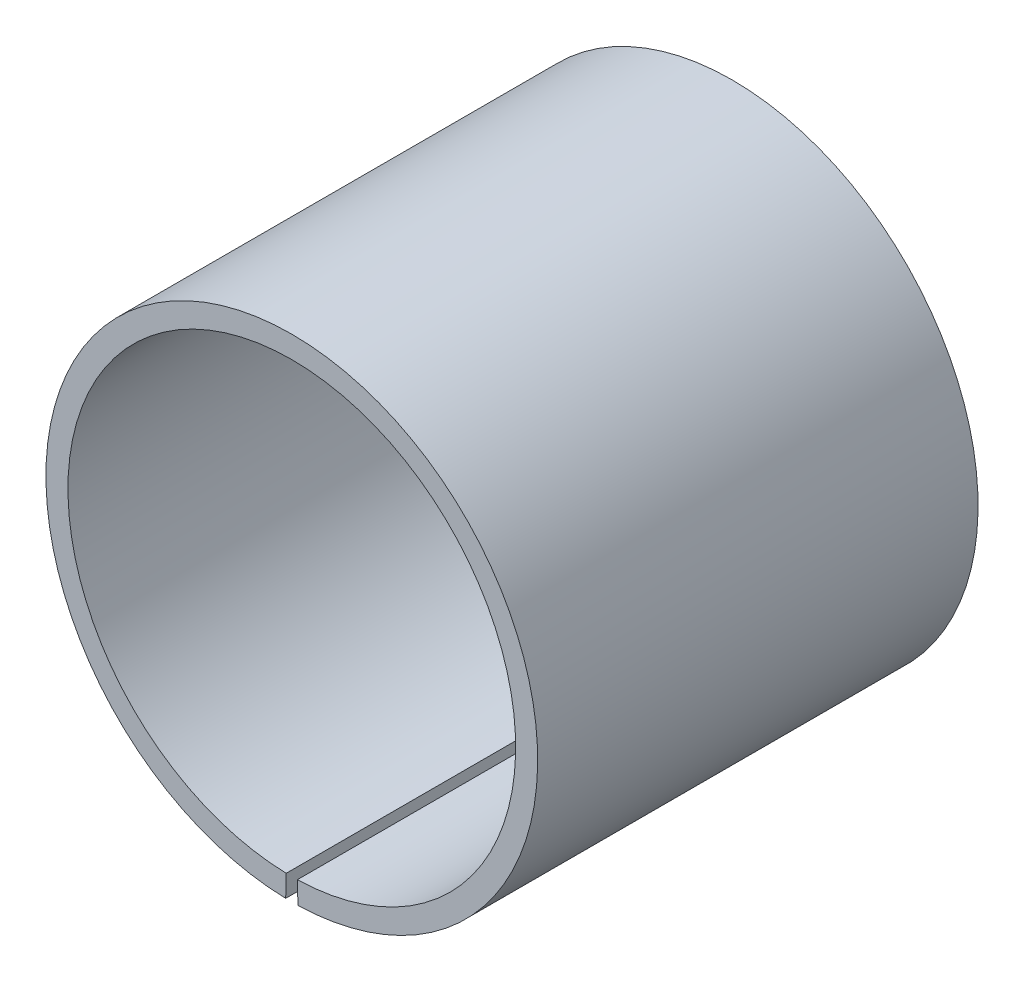
from build123d import *

# Parameters (mm, degrees)
BOSS_EXTRUDE1_DEPTH = 15


with BuildPart() as part:
    # Sketch1 → Boss-Extrude1 (new body, symmetric)
    with BuildSketch(Plane.XY):
        with BuildLine():
            Line((-0.379746263, -15.245271161), (-0.417098355, -16.744806029))
            ThreePointArc((-0.417098355, -16.744806029), (0, 16.75), (0.417098355, -16.744806029))
            Line((0.417098355, -16.744806029), (0.379746263, -15.245271161))
            ThreePointArc((0.379746263, -15.245271161), (0, 15.25), (-0.379746263, -15.245271161))
        make_face()
    extrude(amount=BOSS_EXTRUDE1_DEPTH, both=True)


solid = part.part
